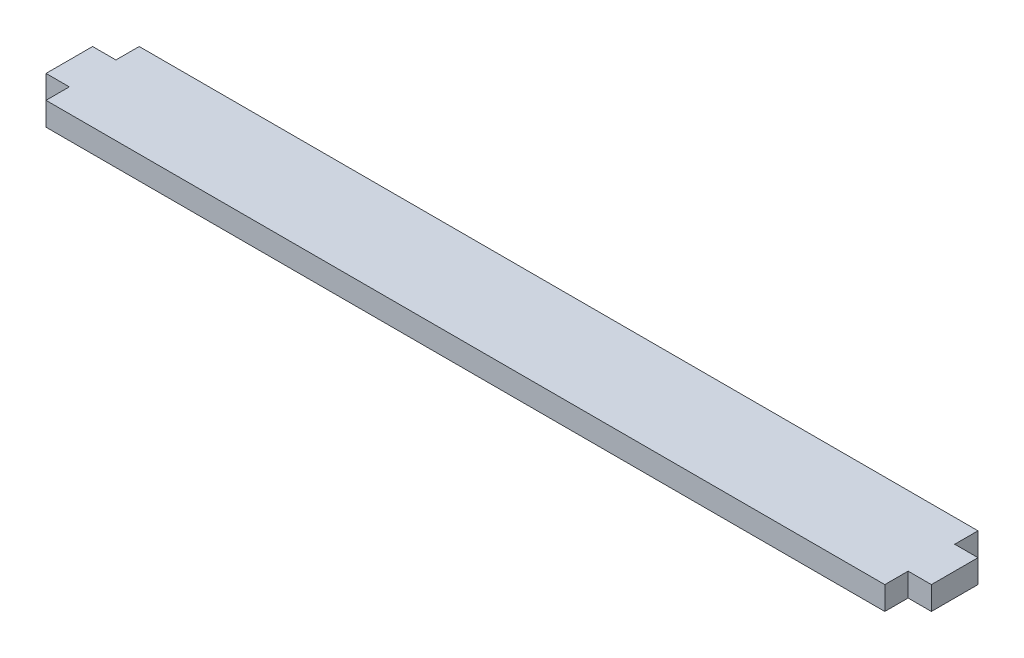
from build123d import *

# Parameters (mm, degrees)
BOSS_EXTRUDE1_DEPTH = 3.175


with BuildPart() as part:
    # Sketch1 → Boss-Extrude1 (new body)
    with BuildSketch(Plane(origin=(0, 0, 0), x_dir=(1, 0, 0), z_dir=(0, 1, 0))):
        Polygon((0, 0), (-114.3, 0), (-114.3, 3.175), (-117.475, 3.175), (-117.475, 9.525), (-114.3, 9.525), (-114.3, 12.7), (0, 12.7), (0, 9.525), (3.175, 9.525), (3.175, 3.175), (0, 3.175), align=None)
    extrude(amount=BOSS_EXTRUDE1_DEPTH)


solid = part.part
